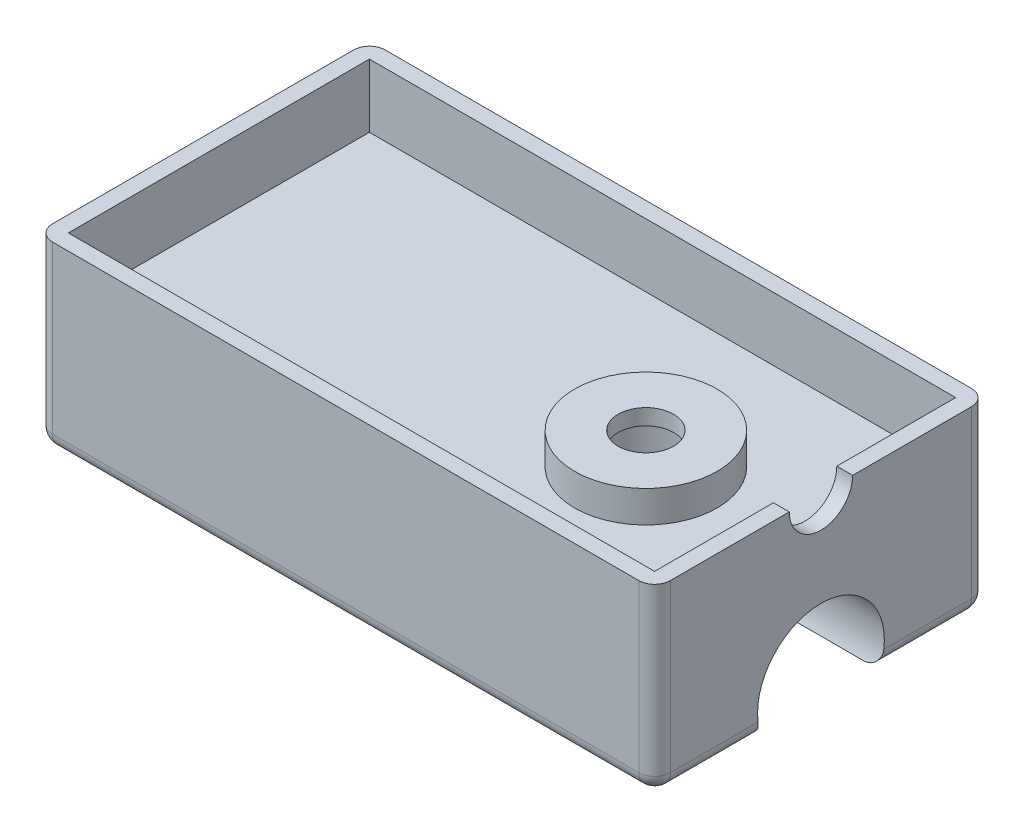
from build123d import *

# Parameters (mm, degrees)
SKETCH1_W           = 39
SKETCH1_H           = 21
BOSS_EXTRUDE1_DEPTH = 11.5
SKETCH3_W           = 37
SKETCH3_H           = 19
CUT_EXTRUDE2_DEPTH  = 4
FILLET1_R           = 1
FILLET2_R           = 1
SKETCH5_R           = 4.5
BOSS_EXTRUDE2_DEPTH = 2
SKETCH6_R           = 3.5
CUT_EXTRUDE4_DEPTH  = 9.5
SKETCH7_R           = 4.5
BOSS_EXTRUDE3_DEPTH = 1
SKETCH8_R           = 1.75
CUT_EXTRUDE5_DEPTH  = 1
CUT_EXTRUDE6_DEPTH  = 1
CUT_EXTRUDE7_DEPTH  = 39


with BuildPart() as part:
    # Sketch1 → Boss-Extrude1 (new body)
    with BuildSketch(Plane(origin=(0, 0, 0), x_dir=(1, 0, 0), z_dir=(0, 1, 0))):
        with Locations((19.5, 10.5)):
            Rectangle(SKETCH1_W, SKETCH1_H)
    extrude(amount=BOSS_EXTRUDE1_DEPTH)

    # Sketch3 → Cut-Extrude2 (cut)
    with BuildSketch(Plane(origin=(0, 11.5, 0), x_dir=(1, 0, 0), z_dir=(0, 1, 0))):
        with Locations((19.5, 10.5)):
            Rectangle(SKETCH3_W, SKETCH3_H)
    extrude(amount=-CUT_EXTRUDE2_DEPTH, mode=Mode.SUBTRACT)

    # Fillet1
    fillet1_edges = [part.edges().sort_by_distance(p)[0] for p in [
        (0, 5.75, -21),
        (39, 5.75, -21),
        (39, 5.75, 0),
        (0, 5.75, 0),
    ]]
    fillet(fillet1_edges, radius=FILLET1_R)

    # Fillet2
    fillet2_edges = [part.edges().sort_by_distance(p)[0] for p in [
        (19.5, 0, 0),
        (0, 0, -10.5),
        (19.5, 0, -21),
        (39, 0, -10.5),
        (0.292893219, 0, -20.707106781),
        (38.707106781, 0, -20.707106781),
        (38.707106781, 0, -0.292893219),
        (0.292893219, 0, -0.292893219),
    ]]
    fillet(fillet2_edges, radius=FILLET2_R)

    # Sketch5 → Boss-Extrude2 (add)
    with BuildSketch(Plane(origin=(0, 7.5, 0), x_dir=(1, 0, 0), z_dir=(0, 1, 0))):
        with Locations((28.01, 10.44)):
            Circle(SKETCH5_R)
    extrude(amount=BOSS_EXTRUDE2_DEPTH)

    # Sketch6 → Cut-Extrude4 (cut)
    with BuildSketch(Plane(origin=(0, 9.5, 0), x_dir=(1, 0, 0), z_dir=(0, 1, 0))):
        with Locations((28.01, 10.44)):
            Circle(SKETCH6_R)
    extrude(amount=-CUT_EXTRUDE4_DEPTH, mode=Mode.SUBTRACT)

    # Sketch7 → Boss-Extrude3 (add)
    with BuildSketch(Plane(origin=(0, 9.5, 0), x_dir=(1, 0, 0), z_dir=(0, 1, 0))):
        with Locations((28.01, 10.44)):
            Circle(SKETCH7_R)
    extrude(amount=-BOSS_EXTRUDE3_DEPTH)

    # Sketch8 → Cut-Extrude5 (cut)
    with BuildSketch(Plane(origin=(0, 9.5, 0), x_dir=(1, 0, 0), z_dir=(0, 1, 0))):
        with Locations((28.01, 10.44)):
            Circle(SKETCH8_R)
    extrude(amount=-CUT_EXTRUDE5_DEPTH, mode=Mode.SUBTRACT)

    # Sketch9 → Cut-Extrude6 (cut)
    with BuildSketch(Plane(origin=(39, 0, 0), x_dir=(0, 0, -1), z_dir=(1, 0, 0))):
        with BuildLine():
            Line((8.5, 11.5), (12.5, 11.5))
            ThreePointArc((12.5, 11.5), (10.5, 9.5), (8.5, 11.5))
        make_face()
    extrude(amount=-CUT_EXTRUDE6_DEPTH, mode=Mode.SUBTRACT)

    # Sketch4 → Cut-Extrude7 (cut)
    with BuildSketch(Plane.ZY):
        with BuildLine():
            Line((-14.208099244, 0), (-6.791900756, 0))
            ThreePointArc((-6.791900756, 0), (-10.5, 5.5), (-14.208099244, 0))
        make_face()
    extrude(amount=-CUT_EXTRUDE7_DEPTH, mode=Mode.SUBTRACT)


solid = part.part
